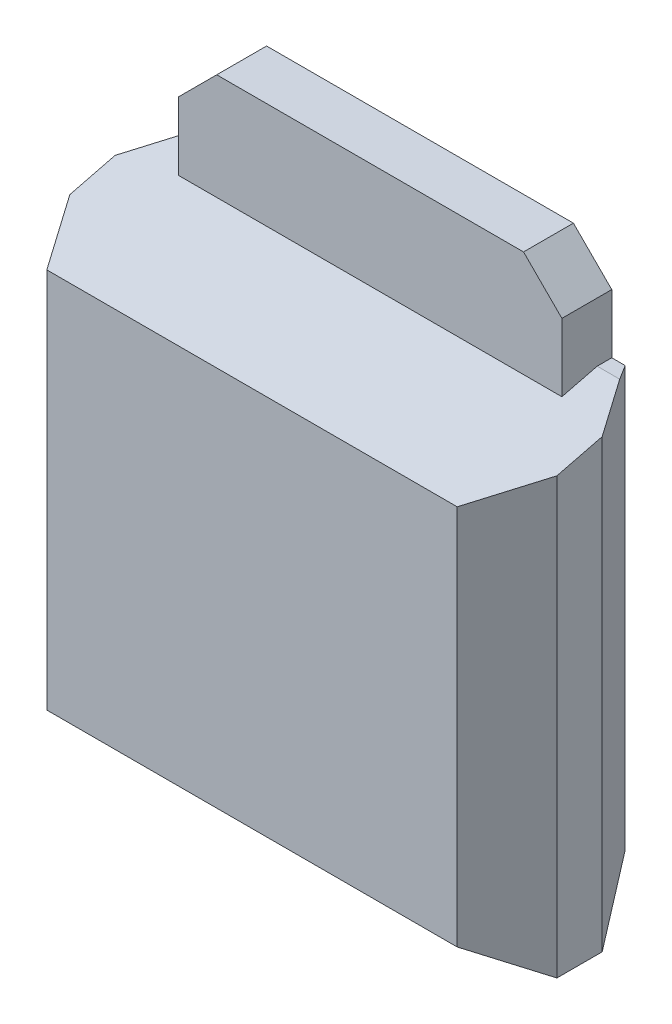
from build123d import *

# Parameters (mm, degrees)
ESQUISSE1_W             = 6.35
ESQUISSE1_H             = 5.97
BOSS_EXTRU_1_DEPTH      = 2.19
CHANFREIN1_SIZE         = 0.8
CHANFREIN1_SIZE2        = 0.5
CHANFREIN2_SIZE         = 0.5
CHANFREIN2_SIZE2        = 0.8
CHANFREIN3_SIZE         = 0.8
CHANFREIN3_SIZE2        = 0.5
CHANFREIN4_SIZE         = 0.5
CHANFREIN4_SIZE2        = 0.8
CHANFREIN5_SIZE         = 0.8
CHANFREIN5_SIZE2        = 0.5
CHANFREIN6_SIZE         = 0.5
CHANFREIN6_SIZE2        = 0.8
CHANFREIN7_SIZE         = 2
CHANFREIN7_SIZE2        = 0.5
ESQUISSE2_W             = 5
ESQUISSE2_H             = 0.65
BOSS_EXTRU_2_DEPTH      = 1.27
BOSS_EXTRU_2_DEPTH_BACK = 5
CHANFREIN8_SIZE         = 0.5


with BuildPart() as part:
    # Esquisse1 → Boss.-Extru.1 (new body)
    with BuildSketch(Plane.XY):
        with Locations((3.175, 2.985)):
            Rectangle(ESQUISSE1_W, ESQUISSE1_H)
    extrude(amount=BOSS_EXTRU_1_DEPTH)

    # Chanfrein1
    chanfrein1_edges = [part.edges().sort_by_distance(p)[0] for p in [
        (6.35, 2.985, 2.19),
    ]]
    chanfrein1_side = [part.faces().sort_by_distance(p)[0] for p in [
        (6.35, 2.985, 1.095),
    ]]
    chamfer(chanfrein1_edges, length=CHANFREIN1_SIZE, length2=CHANFREIN1_SIZE2, reference=chanfrein1_side[0])

    # Chanfrein2
    chanfrein2_edges = [part.edges().sort_by_distance(p)[0] for p in [
        (6.35, 2.985, 0),
    ]]
    chanfrein2_side = [part.faces().sort_by_distance(p)[0] for p in [
        (3.175, 2.985, 0),
    ]]
    chamfer(chanfrein2_edges, length=CHANFREIN2_SIZE, length2=CHANFREIN2_SIZE2, reference=chanfrein2_side[0])

    # Chanfrein3
    chanfrein3_edges = [part.edges().sort_by_distance(p)[0] for p in [
        (2.925, 0, 2.19),
    ]]
    chanfrein3_side = [part.faces().sort_by_distance(p)[0] for p in [
        (3.085907094, 0, 1.095),
    ]]
    chamfer(chanfrein3_edges, length=CHANFREIN3_SIZE, length2=CHANFREIN3_SIZE2, reference=chanfrein3_side[0])

    # Chanfrein4
    chanfrein4_edges = [part.edges().sort_by_distance(p)[0] for p in [
        (2.925, 0, 0),
    ]]
    chanfrein4_side = [part.faces().sort_by_distance(p)[0] for p in [
        (2.925, 2.985, 0),
    ]]
    chamfer(chanfrein4_edges, length=CHANFREIN4_SIZE, length2=CHANFREIN4_SIZE2, reference=chanfrein4_side[0])

    # Chanfrein5
    chanfrein5_edges = [part.edges().sort_by_distance(p)[0] for p in [
        (0, 3.235, 2.19),
    ]]
    chanfrein5_side = [part.faces().sort_by_distance(p)[0] for p in [
        (0, 3.073946398, 1.095),
    ]]
    chamfer(chanfrein5_edges, length=CHANFREIN5_SIZE, length2=CHANFREIN5_SIZE2, reference=chanfrein5_side[0])

    # Chanfrein6
    chanfrein6_edges = [part.edges().sort_by_distance(p)[0] for p in [
        (0, 3.235, 0),
    ]]
    chanfrein6_side = [part.faces().sort_by_distance(p)[0] for p in [
        (2.925, 3.235, 0),
    ]]
    chamfer(chanfrein6_edges, length=CHANFREIN6_SIZE, length2=CHANFREIN6_SIZE2, reference=chanfrein6_side[0])

    # Chanfrein7
    chanfrein7_edges = [part.edges().sort_by_distance(p)[0] for p in [
        (3.175, 5.97, 2.19),
    ]]
    chanfrein7_side = [part.faces().sort_by_distance(p)[0] for p in [
        (3.175, 5.97, 1.095),
    ]]
    chamfer(chanfrein7_edges, length=CHANFREIN7_SIZE, length2=CHANFREIN7_SIZE2, reference=chanfrein7_side[0])

    # Esquisse2 → Boss.-Extru.2 (add, two sides)
    with BuildSketch(Plane(origin=(0, 5.97, 0), x_dir=(-1, 0, 0), z_dir=(0, 1, 0))) as boss_extru_2_sk:
        with Locations((-3.175, 0.325)):
            Rectangle(ESQUISSE2_W, ESQUISSE2_H)
    extrude(amount=BOSS_EXTRU_2_DEPTH)
    extrude(boss_extru_2_sk.sketch, amount=-BOSS_EXTRU_2_DEPTH_BACK)

    # Chanfrein8
    chanfrein8_edges = [part.edges().sort_by_distance(p)[0] for p in [
        (0.675, 7.24, 0.325),
        (5.675, 7.24, 0.325),
    ]]
    chamfer(chanfrein8_edges, length=CHANFREIN8_SIZE)


solid = part.part
